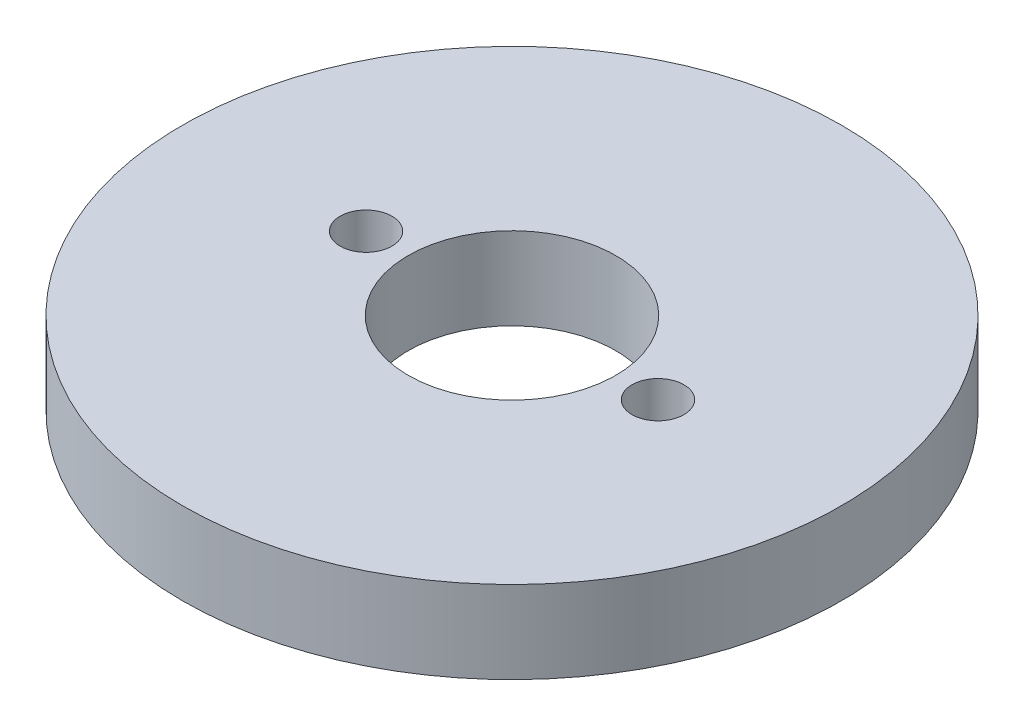
from build123d import *

# Parameters (mm, degrees)
SKETCH1_R           = 50.8
SKETCH1_R_2         = 16
BOSS_EXTRUDE1_DEPTH = 12.7
SKETCH2_R           = 4
CUT_EXTRUDE1_DEPTH  = 12.7


with BuildPart() as part:
    # Sketch1 → Boss-Extrude1 (new body)
    with BuildSketch(Plane(origin=(0, 0, 0), x_dir=(1, 0, 0), z_dir=(0, 1, 0))):
        Circle(SKETCH1_R)
        Circle(SKETCH1_R_2, mode=Mode.SUBTRACT)
    extrude(amount=BOSS_EXTRUDE1_DEPTH)

    # Sketch2 → Cut-Extrude1 (cut)
    with BuildSketch(Plane(origin=(0, 12.7, 0), x_dir=(1, 0, 0), z_dir=(0, 1, 0))):
        with Locations((-22.5, 0)):
            Circle(SKETCH2_R)
        with Locations((22.5, 0)):
            Circle(SKETCH2_R)
    extrude(amount=-CUT_EXTRUDE1_DEPTH, mode=Mode.SUBTRACT)


solid = part.part
